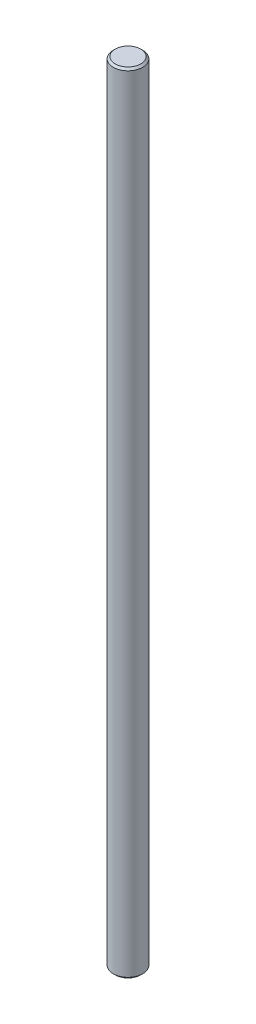
from build123d import *

# Parameters (mm, degrees)
SKETCH1_R           = 4.7625
BOSS_EXTRUDE1_DEPTH = 254
CHAMFER1_SIZE       = 0.635


with BuildPart() as part:
    # Sketch1 → Boss-Extrude1 (new body)
    with BuildSketch(Plane(origin=(0, 0, 0), x_dir=(1, 0, 0), z_dir=(0, 1, 0))):
        Circle(SKETCH1_R)
    extrude(amount=BOSS_EXTRUDE1_DEPTH)

    # Chamfer1
    chamfer1_edges = [part.edges().sort_by_distance(p)[0] for p in [
        (-4.7625, 0, 0),
        (-4.7625, 254, 0),
    ]]
    chamfer(chamfer1_edges, length=CHAMFER1_SIZE)


solid = part.part
